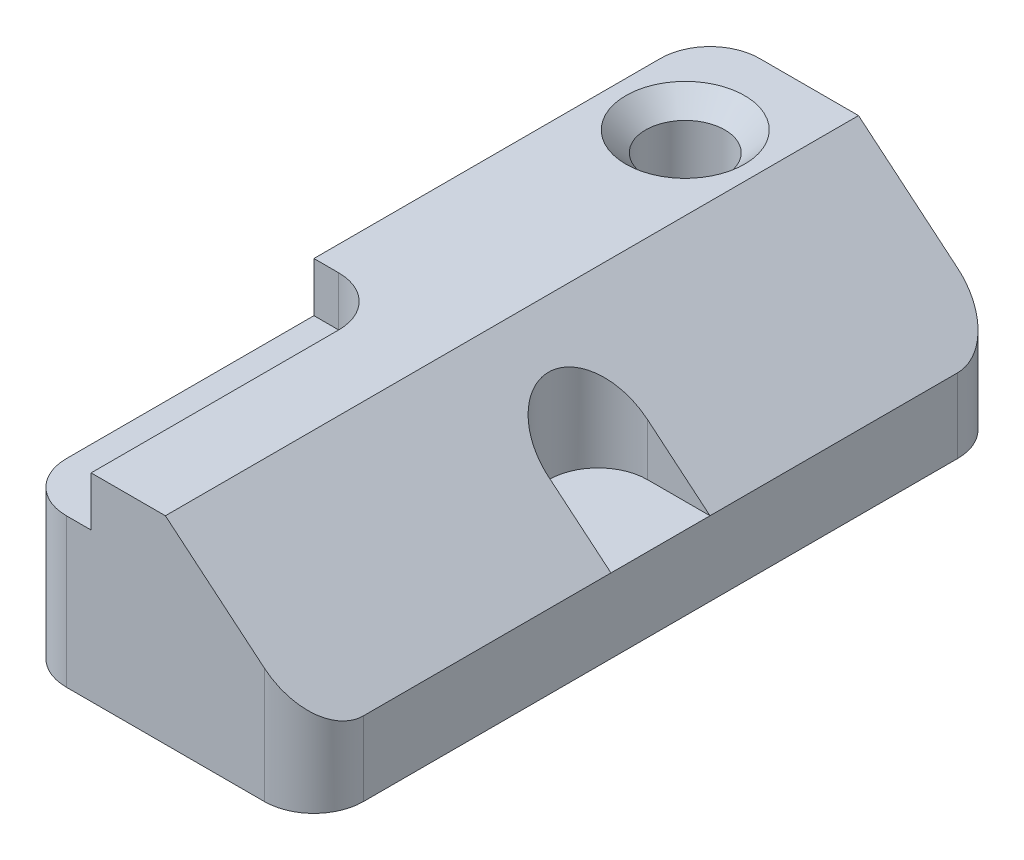
from build123d import *

# Parameters (mm, degrees)
BOSS_EXTRUDE1_DEPTH = 177.8
SKETCH8_R           = 10.16
CUT_EXTRUDE1_DEPTH  = 51.8
CHAMFER1_SIZE       = 5.08
SKETCH9_W           = 19.05
SKETCH9_H           = 76.2
CUT_EXTRUDE2_DEPTH  = 12.7
FILLET1_R           = 12.7
CUT_EXTRUDE3_DEPTH  = 31.75
FILLET2_R           = 12.7


with BuildPart() as part:
    # Sketch1 → Boss-Extrude1 (new body)
    with BuildSketch(Plane.XY):
        Polygon((0, 0), (0, 50.8), (38.1, 50.8), (76.2, 19.05), (76.2, 0), align=None)
    extrude(amount=-BOSS_EXTRUDE1_DEPTH)

    # Sketch8 → Cut-Extrude1 (cut, through all)
    with BuildSketch(Plane(origin=(0, 50.8, 0), x_dir=(1, 0, 0), z_dir=(0, 1, 0))):
        with Locations((19.05, 152.4)):
            Circle(SKETCH8_R)
    extrude(amount=-CUT_EXTRUDE1_DEPTH, mode=Mode.SUBTRACT)

    # Chamfer1
    chamfer1_edges = [part.edges().sort_by_distance(p)[0] for p in [
        (8.89, 50.8, -152.4),
    ]]
    chamfer(chamfer1_edges, length=CHAMFER1_SIZE)

    # Sketch9 → Cut-Extrude2 (cut)
    with BuildSketch(Plane(origin=(0, 50.8, 0), x_dir=(1, 0, 0), z_dir=(0, 1, 0))):
        with Locations((9.525, 38.1)):
            Rectangle(SKETCH9_W, SKETCH9_H)
    extrude(amount=-CUT_EXTRUDE2_DEPTH, mode=Mode.SUBTRACT)

    # Fillet1
    fillet1_edges = [part.edges().sort_by_distance(p)[0] for p in [
        (19.05, 44.45, -76.2),
    ]]
    fillet(fillet1_edges, radius=FILLET1_R)

    # Sketch10 → Cut-Extrude3 (cut)
    with BuildSketch(Plane(origin=(0, 50.8, 0), x_dir=(1, 0, 0), z_dir=(0, 1, 0))):
        with BuildLine():
            Line((76.2, 101.6), (60.198, 101.6))
            ThreePointArc((60.198, 101.6), (47.498, 88.9), (60.198, 76.2))
            Line((60.198, 76.2), (76.2, 76.2))
            Line((76.2, 76.2), (76.2, 101.6))
        make_face()
    extrude(amount=-CUT_EXTRUDE3_DEPTH, mode=Mode.SUBTRACT)

    # Fillet2
    fillet2_edges = [part.edges().sort_by_distance(p)[0] for p in [
        (0, 25.4, -177.8),
        (0, 19.05, 0),
        (76.2, 9.525, 0),
        (76.2, 9.525, -177.8),
    ]]
    fillet(fillet2_edges, radius=FILLET2_R)


solid = part.part
